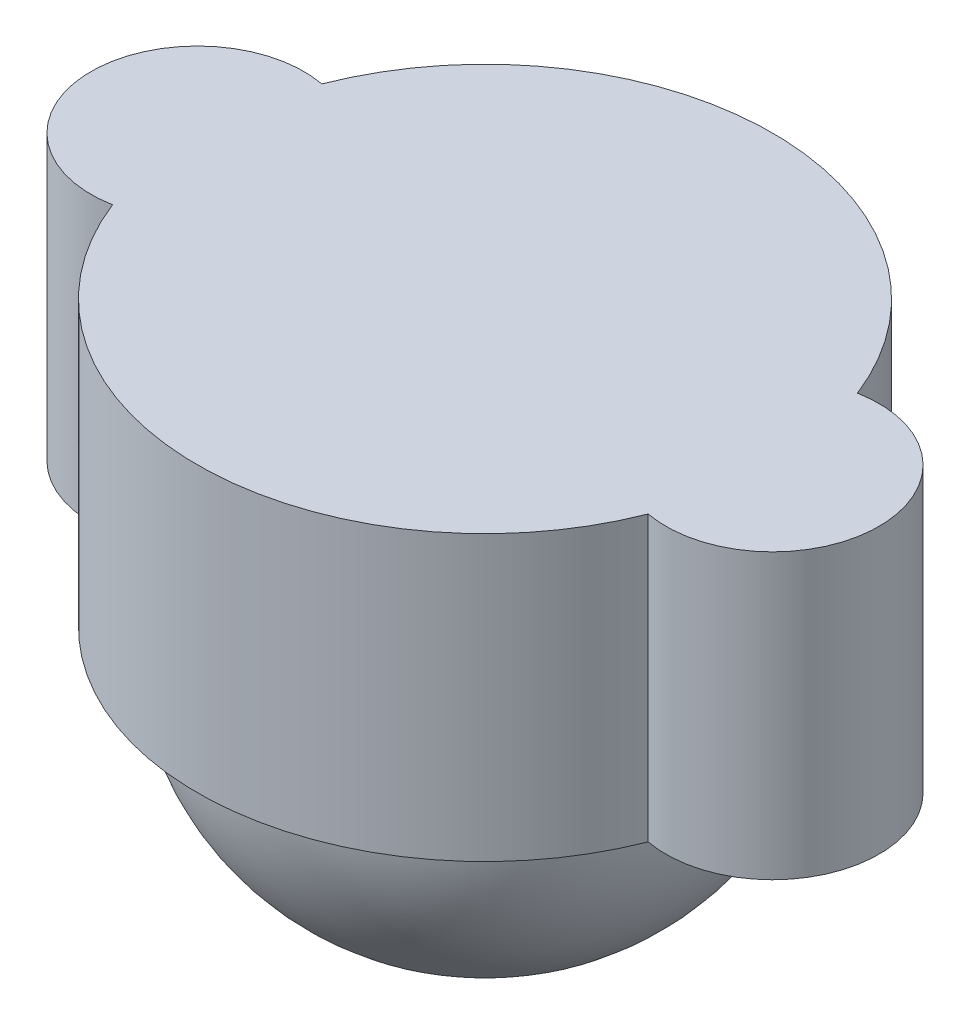
from build123d import *

# Parameters (mm, degrees)
BOSS_EXTRUDE1_DEPTH = 8


with BuildPart() as part:
    # Sketch2 → Boss-Extrude1 (new body)
    with BuildSketch(Plane(origin=(0, 0, 0), x_dir=(1, 0, 0), z_dir=(0, 1, 0))):
        with BuildLine():
            ThreePointArc((-7.544444444, -2.948110925), (0, -8.1), (7.544444444, -2.948110925))
            ThreePointArc((7.544444444, -2.948110925), (11.1, 0), (7.544444444, 2.948110925))
            ThreePointArc((7.544444444, 2.948110925), (0, 8.1), (-7.544444444, 2.948110925))
            ThreePointArc((-7.544444444, 2.948110925), (-11.1, 0), (-7.544444444, -2.948110925))
        make_face()
    extrude(amount=-BOSS_EXTRUDE1_DEPTH)

    # Sketch3 → Revolve1 (revolve)
    with BuildSketch(Plane.XZ.offset(8)):
        with BuildLine():
            Line((0, 7), (0, -7))
            ThreePointArc((0, -7), (-7, 0), (0, 7))
        make_face()
    revolve(axis=Axis((0, -8, 7), (0, 0, -1)))


solid = part.part
